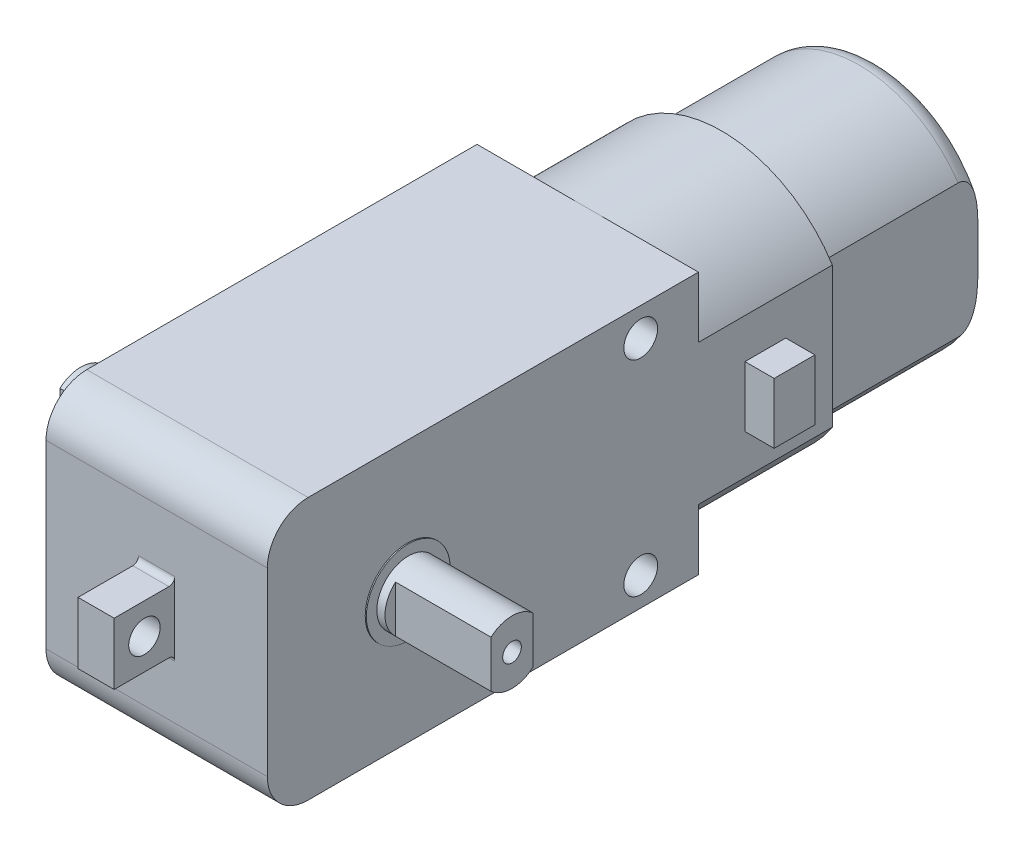
from build123d import *

# Parameters (mm, degrees)
SKETCH1_W                 = 37
SKETCH1_H                 = 22.5
BOSS_EXTRUDE1_DEPTH       = 19
SKETCH2_W                 = 3.1
SKETCH2_H                 = 5.3
BOSS_EXTRUDE2_DEPTH       = 5.2
SKETCH3_R                 = 1.35
CUT_EXTRUDE1_DEPTH        = 12.05
FILLET1_R                 = 3.5
SKETCH4_R                 = 3.6
BOSS_EXTRUDE3_DEPTH       = 0.1
SKETCH5_R                 = 3.6
BOSS_EXTRUDE4_DEPTH       = 0.1
SKETCH6_R                 = 2.7
BOSS_EXTRUDE5_DEPTH       = 8.9
SKETCH7_R                 = 2.7
BOSS_EXTRUDE6_DEPTH       = 8.9
FILLET2_R                 = 0.5
CUT_EXTRUDE2_DEPTH        = 8.2
CUT_EXTRUDE3_DEPTH        = 8.2
M2X0_4_TAPPED_HOLE1_D     = 1.6
M2X0_4_TAPPED_HOLE1_DEPTH = 5.2
M2X0_4_TAPPED_HOLE1_TIP   = 0.480688495
M2X0_4_TAPPED_HOLE2_D     = 1.6
M2X0_4_TAPPED_HOLE2_DEPTH = 5.2
M2X0_4_TAPPED_HOLE2_TIP   = 0.480688495
SKETCH16_R                = 1.95
BOSS_EXTRUDE7_DEPTH       = 2
BOSS_EXTRUDE8_DEPTH       = 11.5
SKETCH18_W                = 3.5
SKETCH18_H                = 5.2
BOSS_EXTRUDE9_DEPTH       = 2.5
SKETCH19_W                = 3.5
SKETCH19_H                = 5.2
BOSS_EXTRUDE10_DEPTH      = 2.5
BOSS_EXTRUDE11_DEPTH      = 13.5
FILLET3_R                 = 1.7
BOSS_EXTRUDE12_DEPTH      = 2
SKETCH25_R                = 1.45
CUT_EXTRUDE5_DEPTH        = 29


with BuildPart() as part:
    # Sketch1 → Boss-Extrude1 (new body)
    with BuildSketch(Plane(origin=(0, 0, 0), x_dir=(0, 0, -1), z_dir=(1, 0, 0))):
        with Locations((-18.5, 0)):
            Rectangle(SKETCH1_W, SKETCH1_H)
    extrude(amount=BOSS_EXTRUDE1_DEPTH)

    # Sketch2 → Boss-Extrude2 (add)
    with BuildSketch(Plane.XY.offset(37)):
        with Locations((9.5, 0)):
            Rectangle(SKETCH2_W, SKETCH2_H)
    extrude(amount=BOSS_EXTRUDE2_DEPTH)

    # Sketch3 → Cut-Extrude1 (cut, through all)
    with BuildSketch(Plane(origin=(11.05, 0, 0), x_dir=(0, 0, -1), z_dir=(1, 0, 0))):
        with Locations((-39.6, 0)):
            Circle(SKETCH3_R)
    extrude(amount=-CUT_EXTRUDE1_DEPTH, mode=Mode.SUBTRACT)

    # Fillet1
    fillet1_edges = [part.edges().sort_by_distance(p)[0] for p in [
        (9.5, -11.25, 37),
        (9.5, 11.25, 37),
    ]]
    fillet(fillet1_edges, radius=FILLET1_R)

    # Sketch4 → Boss-Extrude3 (add)
    with BuildSketch(Plane(origin=(19, 0, 0), x_dir=(0, 0, -1), z_dir=(1, 0, 0))):
        with Locations((-25, 0)):
            Circle(SKETCH4_R)
    extrude(amount=BOSS_EXTRUDE3_DEPTH)

    # Sketch5 → Boss-Extrude4 (add)
    with BuildSketch(Plane.ZY):
        with Locations((25, 0)):
            Circle(SKETCH5_R)
    extrude(amount=BOSS_EXTRUDE4_DEPTH)

    # Sketch6 → Boss-Extrude5 (add)
    with BuildSketch(Plane(origin=(19.1, 0, 0), x_dir=(0, 0, -1), z_dir=(1, 0, 0))):
        with Locations((-25, 0)):
            Circle(SKETCH6_R)
    extrude(amount=BOSS_EXTRUDE5_DEPTH)

    # Sketch7 → Boss-Extrude6 (add)
    with BuildSketch(Plane.ZY.offset(0.1)):
        with Locations((25, 0)):
            Circle(SKETCH7_R)
    extrude(amount=BOSS_EXTRUDE6_DEPTH)

    # Fillet2
    fillet2_edges = [part.edges().sort_by_distance(p)[0] for p in [
        (9.5, 2.65, 37),
        (9.5, -2.65, 37),
    ]]
    fillet(fillet2_edges, radius=FILLET2_R)

    # Sketch8 → Cut-Extrude2 (cut)
    with BuildSketch(Plane(origin=(28, 0, 0), x_dir=(0, 0, -1), z_dir=(1, 0, 0))):
        with BuildLine():
            Line((-26.8, -2.01246118), (-26.8, 2.01246118))
            ThreePointArc((-26.8, 2.01246118), (-27.7, 0), (-26.8, -2.01246118))
        make_face()
        with BuildLine():
            ThreePointArc((-22.3, 0), (-22.535248491, 1.102270384), (-23.2, 2.01246118))
            Line((-23.2, 2.01246118), (-23.2, -2.01246118))
            ThreePointArc((-23.2, -2.01246118), (-22.535248491, -1.102270384), (-22.3, 0))
        make_face()
    extrude(amount=-CUT_EXTRUDE2_DEPTH, mode=Mode.SUBTRACT)

    # Sketch9 → Cut-Extrude3 (cut)
    with BuildSketch(Plane.ZY.offset(9)):
        with BuildLine():
            Line((23.2, -2.01246118), (23.2, 2.01246118))
            ThreePointArc((23.2, 2.01246118), (22.3, 0), (23.2, -2.01246118))
        make_face()
        with BuildLine():
            ThreePointArc((27.7, 0), (27.464751509, 1.102270384), (26.8, 2.01246118))
            Line((26.8, 2.01246118), (26.8, -2.01246118))
            ThreePointArc((26.8, -2.01246118), (27.464751509, -1.102270384), (27.7, 0))
        make_face()
    extrude(amount=-CUT_EXTRUDE3_DEPTH, mode=Mode.SUBTRACT)

    # M2x0.4 Tapped Hole1
    with Locations(Plane(origin=(28, 0, 0), x_dir=(0, 0, -1), z_dir=(1, 0, 0))):
        with Locations((-25, 0)):
            Hole(M2X0_4_TAPPED_HOLE1_D / 2, depth=M2X0_4_TAPPED_HOLE1_DEPTH)
            with Locations((0, 0, -(M2X0_4_TAPPED_HOLE1_DEPTH + M2X0_4_TAPPED_HOLE1_TIP / 2))):  # 118° drill point
                Cone(0, M2X0_4_TAPPED_HOLE1_D / 2, M2X0_4_TAPPED_HOLE1_TIP, mode=Mode.SUBTRACT)

    # M2x0.4 Tapped Hole2
    with Locations(Plane.ZY.offset(9)):
        with Locations((25, 0)):
            Hole(M2X0_4_TAPPED_HOLE2_D / 2, depth=M2X0_4_TAPPED_HOLE2_DEPTH)
            with Locations((0, 0, -(M2X0_4_TAPPED_HOLE2_DEPTH + M2X0_4_TAPPED_HOLE2_TIP / 2))):  # 118° drill point
                Cone(0, M2X0_4_TAPPED_HOLE2_D / 2, M2X0_4_TAPPED_HOLE2_TIP, mode=Mode.SUBTRACT)

    # Sketch16 → Boss-Extrude7 (add)
    with BuildSketch(Plane.ZY):
        with Locations((13.75, 0)):
            Circle(SKETCH16_R)
    extrude(amount=BOSS_EXTRUDE7_DEPTH)

    # Sketch17 → Boss-Extrude8 (add)
    with BuildSketch(Plane(origin=(0, 0, 0), x_dir=(-1, 0, 0), z_dir=(0, 0, -1))):
        with BuildLine():
            Line((-19, 6.025985397), (-19, -6.025985397))
            ThreePointArc((-19, -6.025985397), (-10.560588754, -11.199895156), (-1.3, -7.7021101))
            Line((-1.3, -7.7021101), (-1.3, 7.7021101))
            ThreePointArc((-1.3, 7.7021101), (-10.560588754, 11.199895156), (-19, 6.025985397))
        make_face()
    extrude(amount=BOSS_EXTRUDE8_DEPTH)

    # Sketch18 → Boss-Extrude9 (add)
    with BuildSketch(Plane(origin=(19, 0, 0), x_dir=(0, 0, -1), z_dir=(1, 0, 0))):
        with Locations((5.75, 0)):
            Rectangle(SKETCH18_W, SKETCH18_H)
    extrude(amount=BOSS_EXTRUDE9_DEPTH)

    # Sketch19 → Boss-Extrude10 (add)
    with BuildSketch(Plane.ZY.offset(-1.3)):
        with Locations((-5.75, 0)):
            Rectangle(SKETCH19_W, SKETCH19_H)
    extrude(amount=BOSS_EXTRUDE10_DEPTH)

    # Sketch20 → Boss-Extrude11 (add)
    with BuildSketch(Plane(origin=(0, 0, -11.5), x_dir=(-1, 0, 0), z_dir=(0, 0, -1))):
        with BuildLine():
            Line((-18, 5.728219619), (-18, -5.728219619))
            ThreePointArc((-18, -5.728219619), (-10.518083587, -10.199313987), (-2.3, -7.295375247))
            Line((-2.3, -7.295375247), (-2.3, 7.295375247))
            ThreePointArc((-2.3, 7.295375247), (-10.518083587, 10.199313987), (-18, 5.728219619))
        make_face()
    extrude(amount=BOSS_EXTRUDE11_DEPTH)

    # Fillet3
    fillet3_edges = [part.edges().sort_by_distance(p)[0] for p in [
        (10.518083587, 10.199313987, -25),
        (10.518083587, -10.199313987, -25),
    ]]
    fillet(fillet3_edges, radius=FILLET3_R)

    # Sketch21 → Boss-Extrude12 (add)
    with BuildSketch(Plane(origin=(0, 0, -25), x_dir=(-1, 0, 0), z_dir=(0, 0, -1))):
        with BuildLine():
            Line((-5.5, -3), (-5.5, 3))
            ThreePointArc((-5.5, 3), (-14.5, 0), (-5.5, -3))
        make_face()
    extrude(amount=BOSS_EXTRUDE12_DEPTH)

    # Sketch25 → Cut-Extrude5 (cut, through all)
    with BuildSketch(Plane(origin=(19, 0, 0), x_dir=(0, 0, -1), z_dir=(1, 0, 0))):
        with Locations((-4.95, 8.8)):
            Circle(SKETCH25_R)
        with Locations((-4.95, -8.8)):
            Circle(SKETCH25_R)
    extrude(amount=-CUT_EXTRUDE5_DEPTH, mode=Mode.SUBTRACT)


solid = part.part
